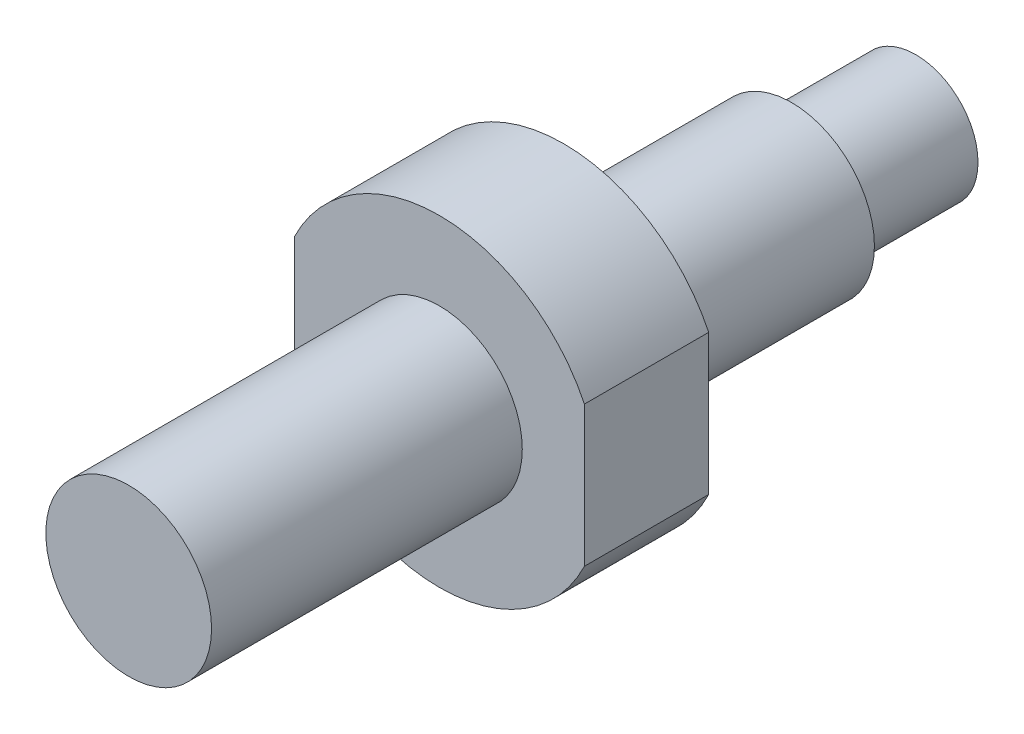
from build123d import *

# Parameters (mm, degrees)
SKETCH_3_W          = 8
SKETCH_3_H          = 16.823898374
CUT_EXTRUDE_1_DEPTH = 10
SKETCH_5_OUTSIDE_W  = 23.858
SKETCH_5_OUTSIDE_H  = 27.858
SKETCH_5_OUTSIDE_R  = 7.77784742
CUT_EXTRUDE_2_DEPTH = 10
SKETCH_6_R          = 3
EXTRUDE_1_DEPTH     = 6


with BuildPart() as part:
    # 草图2 → 旋转1 (revolve)
    with BuildSketch(Plane(origin=(0, 0, 0), x_dir=(0, 0, -1), z_dir=(1, 0, 0))):
        Polygon((0, 0), (0, 4), (15, 4), (15, 9), (21, 9), (21, 4), (32, 4), (32, 0), align=None)
    revolve(axis=Axis((0, 0, 0), (0, 0, -1)))

    # 草图3 → 切除-拉伸1 (cut)
    with BuildSketch(Plane.XY.offset(-15)):
        with Locations((-11, -0.026043186)):
            Rectangle(SKETCH_3_W, SKETCH_3_H)
        with Locations((11, -0.026043186)):
            Rectangle(SKETCH_3_W, SKETCH_3_H)
    extrude(amount=-CUT_EXTRUDE_1_DEPTH, mode=Mode.SUBTRACT)

    # 草图5 outside → 切除-拉伸2 (cut)
    with BuildSketch(Plane(origin=(0, 0, -21), x_dir=(-1, 0, 0), z_dir=(0, 0, -1))):
        Rectangle(SKETCH_5_OUTSIDE_W, SKETCH_5_OUTSIDE_H)
        Circle(SKETCH_5_OUTSIDE_R, mode=Mode.SUBTRACT)
    extrude(amount=-CUT_EXTRUDE_2_DEPTH, mode=Mode.SUBTRACT)

    # 草图6 → 凸台-拉伸1 (add)
    with BuildSketch(Plane(origin=(0, 0, -32), x_dir=(-1, 0, 0), z_dir=(0, 0, -1))):
        Circle(SKETCH_6_R)
    extrude(amount=EXTRUDE_1_DEPTH)


solid = part.part
